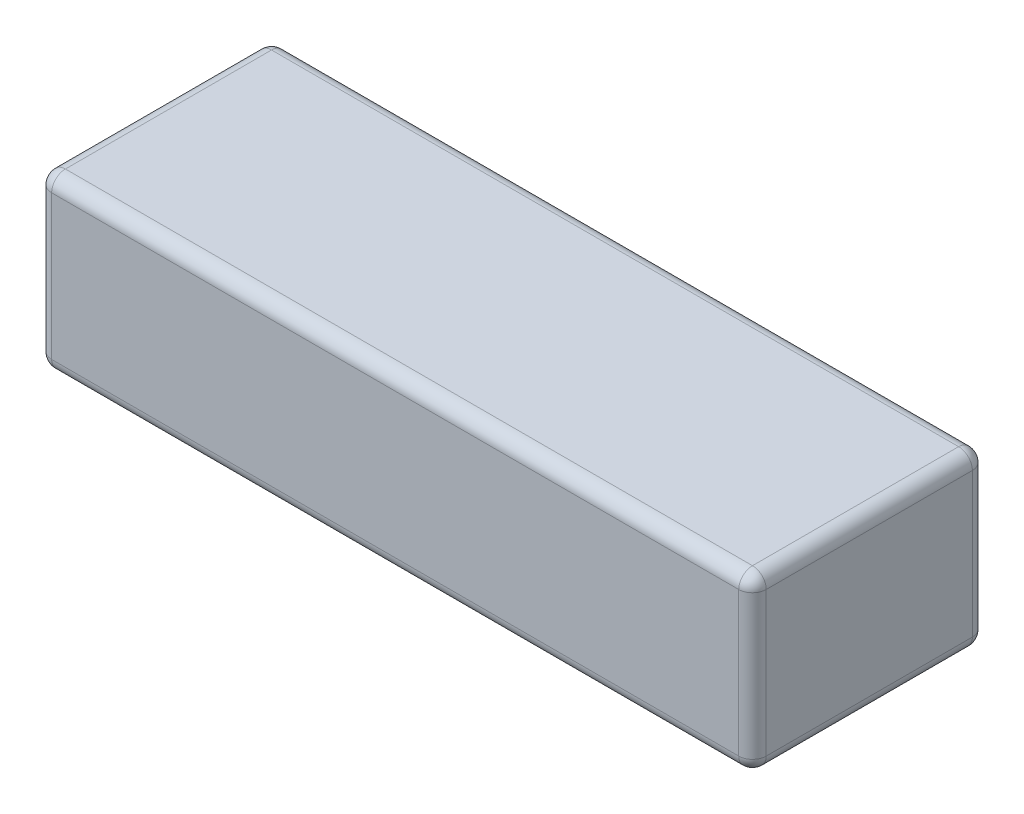
from build123d import *

# Parameters (mm, degrees)
SKETCH1_W           = 104
SKETCH1_H           = 34
BOSS_EXTRUDE1_DEPTH = 25
FILLET1_R           = 2


with BuildPart() as part:
    # Sketch1 → Boss-Extrude1 (new body)
    with BuildSketch(Plane(origin=(0, 0, 0), x_dir=(1, 0, 0), z_dir=(0, 1, 0))):
        Rectangle(SKETCH1_W, SKETCH1_H)
    extrude(amount=BOSS_EXTRUDE1_DEPTH)

    # Fillet1
    fillet1_edges = [part.edges().sort_by_distance(p)[0] for p in [
        (-52, 25, 0),
        (0, 25, 17),
        (52, 25, 0),
        (0, 0, 17),
        (-52, 0, 0),
        (0, 0, -17),
        (52, 0, 0),
        (0, 25, -17),
        (52, 12.5, 17),
        (-52, 12.5, 17),
        (-52, 12.5, -17),
        (52, 12.5, -17),
    ]]
    fillet(fillet1_edges, radius=FILLET1_R)


solid = part.part
